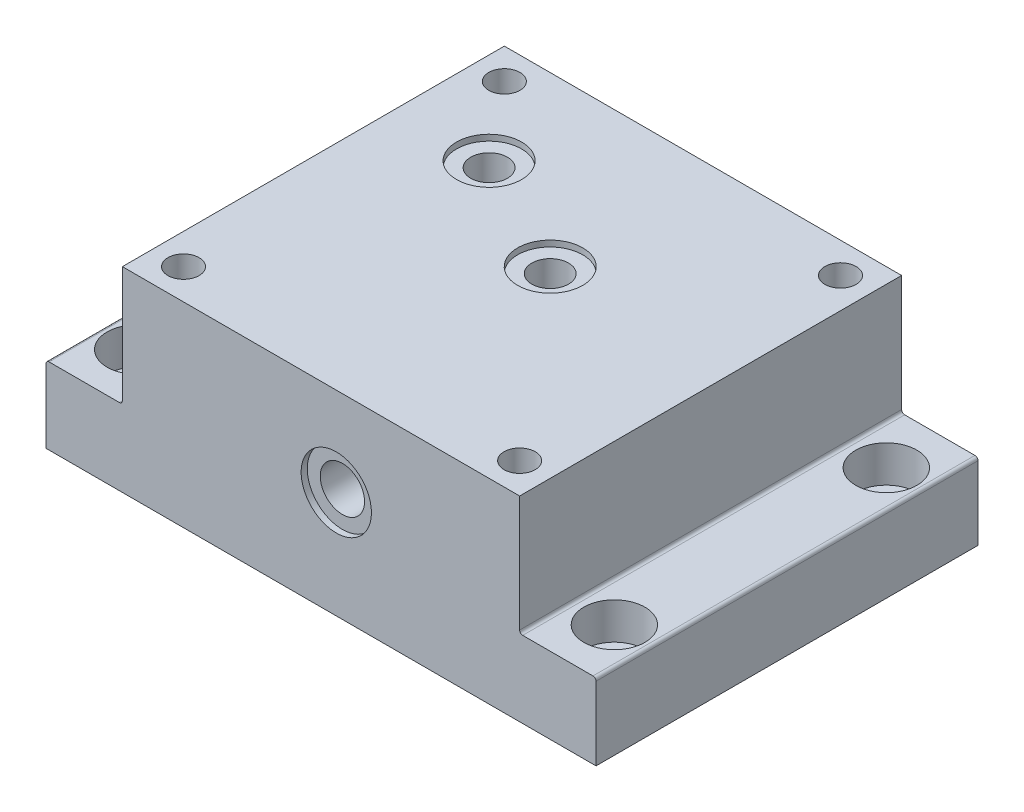
from build123d import *

# Parameters (mm, degrees)
SKETCH_1_W              = 180
SKETCH_1_H              = 125
EXTRUDE_1_DEPTH         = 25
SKETCH_2_W              = 130
SKETCH_2_H              = 125
EXTRUDE_2_DEPTH         = 39
SKETCH_3_R              = 10
CUT_EXTRUDE_1_DEPTH     = 12
SKETCH_4_R              = 10
CUT_EXTRUDE_2_DEPTH     = 12
SKETCH_6_R              = 10
CUT_EXTRUDE_3_DEPTH     = 12
SKETCH_7_R              = 10
CUT_EXTRUDE_4_DEPTH     = 12
SKETCH_9_R              = 6.5
CUT_EXTRUDE_6_DEPTH     = 13
SKETCH_10_R             = 6.5
CUT_EXTRUDE_7_DEPTH     = 13
SKETCH_11_R             = 6.5
CUT_EXTRUDE_8_DEPTH     = 13
SKETCH_12_R             = 6.5
CUT_EXTRUDE_9_DEPTH     = 13
HOLE_WIZARD_M12_1_D     = 10.2
HOLE_WIZARD_M12_1_DEPTH = 25
HOLE_WIZARD_M12_1_TIP   = 3.064389157
HOLE_WIZARD_M12_2_D     = 10.2
HOLE_WIZARD_M12_2_DEPTH = 25
HOLE_WIZARD_M12_2_TIP   = 3.064389157
HOLE_WIZARD_M12_3_D     = 10.2
HOLE_WIZARD_M12_3_DEPTH = 25
HOLE_WIZARD_M12_3_TIP   = 3.064389157
HOLE_WIZARD_M12_4_D     = 10.2
HOLE_WIZARD_M12_4_DEPTH = 25
HOLE_WIZARD_M12_4_TIP   = 3.064389157
SKETCH_23_R             = 10.65
CUT_EXTRUDE_12_DEPTH    = 2
HOLE_WIZARD_M12_5_D     = 10.2
HOLE_WIZARD_M12_5_DEPTH = 25
HOLE_WIZARD_M12_5_TIP   = 3.064389157
HOLE_WIZARD_M12_6_D     = 10.2
HOLE_WIZARD_M12_6_DEPTH = 25
HOLE_WIZARD_M12_6_TIP   = 3.064389157
HOLE_WIZARD_M12_7_D     = 10.2
HOLE_WIZARD_M12_7_DEPTH = 25
HOLE_WIZARD_M12_7_TIP   = 3.064389157
FILLET_7_R              = 1
FILLET_8_R              = 1
FILLET_10_R             = 1
SKETCH_33_R             = 10.65
CUT_EXTRUDE_13_DEPTH    = 1.97
SKETCH_36_R             = 11.5
CUT_EXTRUDE_15_DEPTH    = 2
M16X1_5_2_D             = 14.5
M16X1_5_2_DEPTH         = 14
M16X1_5_2_TIP           = 4.356239488
SKETCH_38_R             = 6
CUT_EXTRUDE_16_DEPTH    = 63.03
MM_1_D                  = 12
MM_1_DEPTH              = 33.63
MM_1_TIP                = 3.605163714
SKETCH_41_R             = 11.5
CUT_EXTRUDE_17_DEPTH    = 2
SKETCH_39_R             = 10.65
CUT_EXTRUDE_18_DEPTH    = 1.97
CUT_EXTRUDE_19_REACH    = 125
SKETCH_42_R             = 6
M16X1_5_3_D             = 14.5
M16X1_5_3_DEPTH         = 14
M16X1_5_3_TIP           = 4.356239488
FILLET_11_R             = 1


with BuildPart() as part:
    # 草图1 → 凸台-拉伸1 (new body)
    with BuildSketch(Plane(origin=(0, 0, 0), x_dir=(1, 0, 0), z_dir=(0, 1, 0))):
        Rectangle(SKETCH_1_W, SKETCH_1_H)
    extrude(amount=EXTRUDE_1_DEPTH)

    # 草图2 → 凸台-拉伸2 (add)
    with BuildSketch(Plane(origin=(0, 25, 0), x_dir=(1, 0, 0), z_dir=(0, 1, 0))):
        Rectangle(SKETCH_2_W, SKETCH_2_H)
    extrude(amount=EXTRUDE_2_DEPTH)

    # 草图3 → 切除-拉伸1 (cut)
    with BuildSketch(Plane(origin=(0, 25, 0), x_dir=(1, 0, 0), z_dir=(0, 1, 0))):
        with Locations((-78, 44.5)):
            Circle(SKETCH_3_R)
    extrude(amount=-CUT_EXTRUDE_1_DEPTH, mode=Mode.SUBTRACT)

    # 草图4 → 切除-拉伸2 (cut)
    with BuildSketch(Plane(origin=(0, 25, 0), x_dir=(1, 0, 0), z_dir=(0, 1, 0))):
        with Locations((78, 44.5)):
            Circle(SKETCH_4_R)
    extrude(amount=-CUT_EXTRUDE_2_DEPTH, mode=Mode.SUBTRACT)

    # 草图6 → 切除-拉伸3 (cut)
    with BuildSketch(Plane(origin=(0, 25, 0), x_dir=(1, 0, 0), z_dir=(0, 1, 0))):
        with Locations((-78, -44.5)):
            Circle(SKETCH_6_R)
    extrude(amount=-CUT_EXTRUDE_3_DEPTH, mode=Mode.SUBTRACT)

    # 草图7 → 切除-拉伸4 (cut)
    with BuildSketch(Plane(origin=(0, 25, 0), x_dir=(1, 0, 0), z_dir=(0, 1, 0))):
        with Locations((78, -44.5)):
            Circle(SKETCH_7_R)
    extrude(amount=-CUT_EXTRUDE_4_DEPTH, mode=Mode.SUBTRACT)

    # 草图9 → 切除-拉伸6 (cut)
    with BuildSketch(Plane(origin=(0, 13, 0), x_dir=(1, 0, 0), z_dir=(0, 1, 0))):
        with Locations((-78, -44.5)):
            Circle(SKETCH_9_R)
    extrude(amount=-CUT_EXTRUDE_6_DEPTH, mode=Mode.SUBTRACT)

    # 草图10 → 切除-拉伸7 (cut)
    with BuildSketch(Plane(origin=(0, 13, 0), x_dir=(1, 0, 0), z_dir=(0, 1, 0))):
        with Locations((-78, 44.5)):
            Circle(SKETCH_10_R)
    extrude(amount=-CUT_EXTRUDE_7_DEPTH, mode=Mode.SUBTRACT)

    # 草图11 → 切除-拉伸8 (cut)
    with BuildSketch(Plane(origin=(0, 13, 0), x_dir=(1, 0, 0), z_dir=(0, 1, 0))):
        with Locations((78, 44.5)):
            Circle(SKETCH_11_R)
    extrude(amount=-CUT_EXTRUDE_8_DEPTH, mode=Mode.SUBTRACT)

    # 草图12 → 切除-拉伸9 (cut)
    with BuildSketch(Plane(origin=(0, 13, 0), x_dir=(1, 0, 0), z_dir=(0, 1, 0))):
        with Locations((78, -44.5)):
            Circle(SKETCH_12_R)
    extrude(amount=-CUT_EXTRUDE_9_DEPTH, mode=Mode.SUBTRACT)

    # M12 螺纹孔1
    with Locations(Plane(origin=(0, 64, 0), x_dir=(1, 0, 0), z_dir=(0, 1, 0))):
        with Locations((-55, 52.5)):
            Hole(HOLE_WIZARD_M12_1_D / 2, depth=HOLE_WIZARD_M12_1_DEPTH)
            with Locations((0, 0, -(HOLE_WIZARD_M12_1_DEPTH + HOLE_WIZARD_M12_1_TIP / 2))):  # 118° drill point
                Cone(0, HOLE_WIZARD_M12_1_D / 2, HOLE_WIZARD_M12_1_TIP, mode=Mode.SUBTRACT)

    # M12 螺纹孔2
    with Locations(Plane(origin=(55, 64, -52.5), x_dir=(0, 0, 1), z_dir=(0, 1, 0))):
        with Locations((0, 0)):
            Hole(HOLE_WIZARD_M12_2_D / 2, depth=HOLE_WIZARD_M12_2_DEPTH)
            with Locations((0, 0, -(HOLE_WIZARD_M12_2_DEPTH + HOLE_WIZARD_M12_2_TIP / 2))):  # 118° drill point
                Cone(0, HOLE_WIZARD_M12_2_D / 2, HOLE_WIZARD_M12_2_TIP, mode=Mode.SUBTRACT)

    # M12 螺纹孔3
    with Locations(Plane(origin=(-55, 64, 52.5), x_dir=(0, 0, 1), z_dir=(0, 1, 0))):
        with Locations((0, 0)):
            Hole(HOLE_WIZARD_M12_3_D / 2, depth=HOLE_WIZARD_M12_3_DEPTH)
            with Locations((0, 0, -(HOLE_WIZARD_M12_3_DEPTH + HOLE_WIZARD_M12_3_TIP / 2))):  # 118° drill point
                Cone(0, HOLE_WIZARD_M12_3_D / 2, HOLE_WIZARD_M12_3_TIP, mode=Mode.SUBTRACT)

    # M12 螺纹孔4
    with Locations(Plane(origin=(55, 64, 52.5), x_dir=(0, 0, 1), z_dir=(0, 1, 0))):
        with Locations((0, 0)):
            Hole(HOLE_WIZARD_M12_4_D / 2, depth=HOLE_WIZARD_M12_4_DEPTH)
            with Locations((0, 0, -(HOLE_WIZARD_M12_4_DEPTH + HOLE_WIZARD_M12_4_TIP / 2))):  # 118° drill point
                Cone(0, HOLE_WIZARD_M12_4_D / 2, HOLE_WIZARD_M12_4_TIP, mode=Mode.SUBTRACT)

    # 草图23 → 切除-拉伸12 (cut)
    with BuildSketch(Plane.XZ):
        with Locations((-35, -27.5)):
            Circle(SKETCH_23_R)
    extrude(amount=-CUT_EXTRUDE_12_DEPTH, mode=Mode.SUBTRACT)

    # M12 螺纹孔5
    with Locations(Plane(origin=(55, 64, -52.5), x_dir=(0, 0, 1), z_dir=(0, 1, 0))):
        with Locations((0, 0)):
            Hole(HOLE_WIZARD_M12_5_D / 2, depth=HOLE_WIZARD_M12_5_DEPTH)
            with Locations((0, 0, -(HOLE_WIZARD_M12_5_DEPTH + HOLE_WIZARD_M12_5_TIP / 2))):  # 118° drill point
                Cone(0, HOLE_WIZARD_M12_5_D / 2, HOLE_WIZARD_M12_5_TIP, mode=Mode.SUBTRACT)

    # M12 螺纹孔6
    with Locations(Plane(origin=(-55, 64, 52.5), x_dir=(0, 0, 1), z_dir=(0, 1, 0))):
        with Locations((0, 0)):
            Hole(HOLE_WIZARD_M12_6_D / 2, depth=HOLE_WIZARD_M12_6_DEPTH)
            with Locations((0, 0, -(HOLE_WIZARD_M12_6_DEPTH + HOLE_WIZARD_M12_6_TIP / 2))):  # 118° drill point
                Cone(0, HOLE_WIZARD_M12_6_D / 2, HOLE_WIZARD_M12_6_TIP, mode=Mode.SUBTRACT)

    # M12 螺纹孔7
    with Locations(Plane(origin=(55, 64, 52.5), x_dir=(0, 0, 1), z_dir=(0, 1, 0))):
        with Locations((0, 0)):
            Hole(HOLE_WIZARD_M12_7_D / 2, depth=HOLE_WIZARD_M12_7_DEPTH)
            with Locations((0, 0, -(HOLE_WIZARD_M12_7_DEPTH + HOLE_WIZARD_M12_7_TIP / 2))):  # 118° drill point
                Cone(0, HOLE_WIZARD_M12_7_D / 2, HOLE_WIZARD_M12_7_TIP, mode=Mode.SUBTRACT)

    # 圆角7
    fillet_7_edges = [part.edges().sort_by_distance(p)[0] for p in [
        (-90, 25, 0),
    ]]
    fillet(fillet_7_edges, radius=FILLET_7_R)

    # 圆角8
    fillet_8_edges = [part.edges().sort_by_distance(p)[0] for p in [
        (-65, 25, 0),
    ]]
    fillet(fillet_8_edges, radius=FILLET_8_R)

    # 圆角10
    fillet_10_edges = [part.edges().sort_by_distance(p)[0] for p in [
        (65, 25, 0),
    ]]
    fillet(fillet_10_edges, radius=FILLET_10_R)

    # 草图33 → 切除-拉伸13 (cut)
    with BuildSketch(Plane(origin=(0, 64, 0), x_dir=(1, 0, 0), z_dir=(0, 1, 0))):
        with Locations((-35, 27.5)):
            Circle(SKETCH_33_R)
    extrude(amount=-CUT_EXTRUDE_13_DEPTH, mode=Mode.SUBTRACT)

    # 草图36 → 切除-拉伸15 (cut)
    with BuildSketch(Plane.XZ):
        with Locations((-35, -27.5)):
            Circle(SKETCH_36_R)
    extrude(amount=-CUT_EXTRUDE_15_DEPTH, mode=Mode.SUBTRACT)

    # M16x1.5 螺纹孔2
    with Locations(Plane(origin=(-35, 0, -27.5), x_dir=(0, 0, -1), z_dir=(0, -1, 0))):
        with Locations((0, 0)):
            Hole(M16X1_5_2_D / 2, depth=M16X1_5_2_DEPTH)
            with Locations((0, 0, -(M16X1_5_2_DEPTH + M16X1_5_2_TIP / 2))):  # 118° drill point
                Cone(0, M16X1_5_2_D / 2, M16X1_5_2_TIP, mode=Mode.SUBTRACT)

    # 草图38 → 切除-拉伸16 (cut, through all)
    with BuildSketch(Plane(origin=(0, 62.03, 0), x_dir=(1, 0, 0), z_dir=(0, 1, 0))):
        with Locations((-35, 27.5)):
            Circle(SKETCH_38_R)
    extrude(amount=-CUT_EXTRUDE_16_DEPTH, mode=Mode.SUBTRACT)

    # 大小mm 暗销孔1
    with Locations(Plane(origin=(5, 64, -7.5), x_dir=(0, 0, 1), z_dir=(0, 1, 0))):
        with Locations((0, 0)):
            Hole(MM_1_D / 2, depth=MM_1_DEPTH)
            with Locations((0, 0, -(MM_1_DEPTH + MM_1_TIP / 2))):  # 118° drill point
                Cone(0, MM_1_D / 2, MM_1_TIP, mode=Mode.SUBTRACT)

    # 草图41 → 切除-拉伸17 (cut)
    with BuildSketch(Plane.XY.offset(62.5)):
        with Locations((5, 35)):
            Circle(SKETCH_41_R)
    extrude(amount=-CUT_EXTRUDE_17_DEPTH, mode=Mode.SUBTRACT)

    # 草图39 → 切除-拉伸18 (cut)
    with BuildSketch(Plane(origin=(0, 64, 0), x_dir=(1, 0, 0), z_dir=(0, 1, 0))):
        with Locations((5, 7.5)):
            Circle(SKETCH_39_R)
    extrude(amount=-CUT_EXTRUDE_18_DEPTH, mode=Mode.SUBTRACT)

    # 草图42 → 切除-拉伸19 (cut, up to next)
    with BuildSketch(Plane.XY.offset(60.5), mode=Mode.PRIVATE) as cut_extrude_19_sk1:
        with Locations((5, 35)):
            Circle(SKETCH_42_R)
    cut_extrude_19_tool1 = extrude(cut_extrude_19_sk1.sketch, amount=-CUT_EXTRUDE_19_REACH, mode=Mode.PRIVATE) & part.part
    add(cut_extrude_19_tool1.solids().sort_by_distance((5, 35, 60.5))[0], mode=Mode.SUBTRACT)

    # M16x1.5 螺纹孔3
    with Locations(Plane(origin=(5, 35, 60.5), x_dir=(1, 0, 0), z_dir=(0, 0, 1))):
        with Locations((0, 0)):
            Hole(M16X1_5_3_D / 2, depth=M16X1_5_3_DEPTH)
            with Locations((0, 0, -(M16X1_5_3_DEPTH + M16X1_5_3_TIP / 2))):  # 118° drill point
                Cone(0, M16X1_5_3_D / 2, M16X1_5_3_TIP, mode=Mode.SUBTRACT)

    # 圆角11
    fillet_11_edges = [part.edges().sort_by_distance(p)[0] for p in [
        (90, 25, 0),
    ]]
    fillet(fillet_11_edges, radius=FILLET_11_R)


solid = part.part
